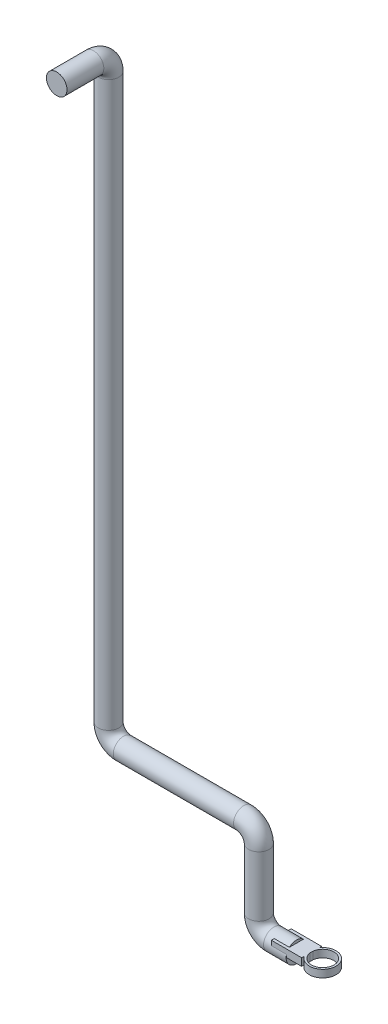
from build123d import *

# Parameters (mm, degrees)
CROQUIS1_R              = 13.7
CROQUIS2_W              = 104.810760898
CROQUIS2_H              = 208.017118972
CORTAR_EXTRUIR2_DEPTH   = 81
CROQUIS3_R              = 17.762543943
CROQUIS3_R_2            = 15
SALIENTE_EXTRUIR1_DEPTH = 10
CROQUIS4_W              = 40.294914154
CROQUIS4_H              = 26.389647966
SALIENTE_EXTRUIR2_DEPTH = 10


with BuildPart() as part:
    # Barrer1: sweep along a curve in space
    with BuildLine() as barrer1_path:
        Line((0, 0, 0), (-30, 0, 0))
        ThreePointArc((-30, 0, 0), (-44.142135624, 5.857864376, 0), (-50, 20, 0))
        Line((-50, 20, 0), (-50, 100, 0))
        ThreePointArc((-50, 100, 0), (-55.857864376, 114.142135624, 0), (-70, 120, 0))
        Line((-70, 120, 0), (-230, 120, 0))
        ThreePointArc((-230, 120, 0), (-244.142135624, 125.857864376, 0), (-250, 140, 0))
        Line((-250, 140, 0), (-250, 890, 0))
        ThreePointArc((-250, 890, 0), (-250, 904.142135624, 5.857864376), (-250, 910, 20))
        Line((-250, 910, 20), (-250, 910, 80))
        ThreePointArc((-250, 910, 80), (-250, 915.857864376, 94.142135624), (-250, 930, 100))
        Line((-250, 930, 100), (-250, 940, 100))
        ThreePointArc((-250, 940, 100), (-250, 954.142135624, 105.857864376), (-250, 960, 120))
        Line((-250, 960, 120), (-250, 960, 150))
    # Croquis1 → Barrer1 (sweep)
    with BuildSketch(Plane(origin=(0, 0, 0), x_dir=(0, 0, -1), z_dir=(1, 0, 0))):
        Circle(CROQUIS1_R)
    sweep(path=barrer1_path.line)

    # Croquis2 → Cortar-Extruir2 (cut)
    with BuildSketch(Plane.XY.offset(150)):
        with Locations((-250, 960)):
            Rectangle(CROQUIS2_W, CROQUIS2_H)
    extrude(amount=-CORTAR_EXTRUIR2_DEPTH, mode=Mode.SUBTRACT)



with BuildPart() as body_2:
    # Croquis3 → Saliente-Extruir1 (new body)
    with BuildSketch(Plane(origin=(0, 0, 0), x_dir=(1, 0, 0), z_dir=(0, 1, 0))):
        with Locations((35, 0)):
            Circle(CROQUIS3_R)
        with Locations((35, 0)):
            Circle(CROQUIS3_R_2, mode=Mode.SUBTRACT)
    extrude(amount=SALIENTE_EXTRUIR1_DEPTH)


with BuildPart() as part_1:
    add(part.part)

    add(body_2.part)  # Saliente-Extruir2 merges body 2
    # Croquis4 → Saliente-Extruir2 (add)
    with BuildSketch(Plane(origin=(0, 0, 0), x_dir=(1, 0, 0), z_dir=(0, 1, 0))):
        Rectangle(CROQUIS4_W, CROQUIS4_H)
    extrude(amount=SALIENTE_EXTRUIR2_DEPTH)


solid = part_1.part
